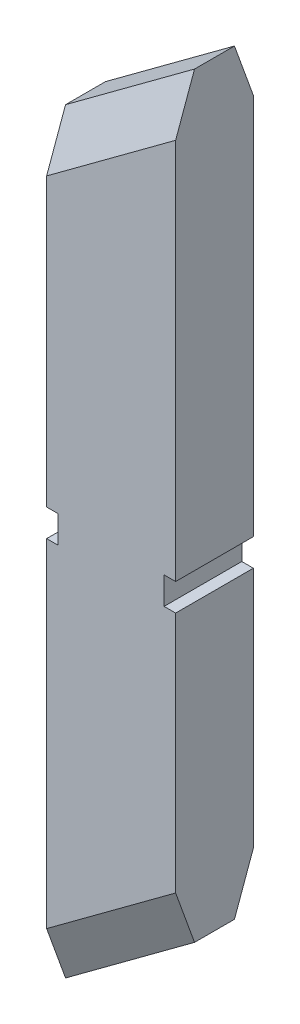
from build123d import *

# Parameters (mm, degrees)
BOSS_EXTRUDE1_DEPTH     = 3.7
CHAMFER1_SIZE           = 0.9
CHAMFER1_SIZE2          = 2
CHAMFER2_SIZE           = 2
CHAMFER2_SIZE2          = 0.9
CHAMFER4_SIZE           = 0.9
CHAMFER4_SIZE2          = 2
CHAMFER5_SIZE           = 2
CHAMFER5_SIZE2          = 0.9
CUT_EXTRUDE2_DEPTH      = 1
CUT_EXTRUDE2_DEPTH_BACK = 4.7
CUT_EXTRUDE4_DEPTH      = 1
CUT_EXTRUDE4_DEPTH_BACK = 4.7


with BuildPart() as part:
    # Sketch1 → Boss-Extrude1 (new body)
    with BuildSketch(Plane.XY):
        Polygon((2.936521739, 23.386304348), (2.936521739, -12.613695652), (-3.203478261, -17.151956522), (-3.203478261, 18.848043478), align=None)
    extrude(amount=BOSS_EXTRUDE1_DEPTH)

    # Chamfer1
    chamfer1_edges = [part.edges().sort_by_distance(p)[0] for p in [
        (-0.133478261, 21.117173913, 3.7),
    ]]
    chamfer1_side = [part.faces().sort_by_distance(p)[0] for p in [
        (-0.133478261, 21.117173913, 1.85),
    ]]
    chamfer(chamfer1_edges, length=CHAMFER1_SIZE, length2=CHAMFER1_SIZE2, reference=chamfer1_side[0])

    # Chamfer2
    chamfer2_edges = [part.edges().sort_by_distance(p)[0] for p in [
        (-0.133478261, 21.117173913, 0),
    ]]
    chamfer2_side = [part.faces().sort_by_distance(p)[0] for p in [
        (-0.133478261, 3.117173913, 0),
    ]]
    chamfer(chamfer2_edges, length=CHAMFER2_SIZE, length2=CHAMFER2_SIZE2, reference=chamfer2_side[0])

    # Chamfer4
    chamfer4_edges = [part.edges().sort_by_distance(p)[0] for p in [
        (-0.133478261, -14.882826087, 3.7),
    ]]
    chamfer4_side = [part.faces().sort_by_distance(p)[0] for p in [
        (-0.133478261, -14.882826087, 1.85),
    ]]
    chamfer(chamfer4_edges, length=CHAMFER4_SIZE, length2=CHAMFER4_SIZE2, reference=chamfer4_side[0])

    # Chamfer5
    chamfer5_edges = [part.edges().sort_by_distance(p)[0] for p in [
        (-0.133478261, -14.882826087, 0),
    ]]
    chamfer5_side = [part.faces().sort_by_distance(p)[0] for p in [
        (-0.133478261, 1.873665248, 0),
    ]]
    chamfer(chamfer5_edges, length=CHAMFER5_SIZE, length2=CHAMFER5_SIZE2, reference=chamfer5_side[0])

    # Sketch2 → Cut-Extrude2 (cut, two sides)
    with BuildSketch(Plane.XY.offset(3.7)) as cut_extrude2_sk:
        Polygon((-58.837345155, 2.711026149), (-3.203478261, 2.711026149), (-2.653478261, 2.711026149), (-2.653478261, 1.411026149), (-3.203478261, 1.411026149), (-58.837345155, 1.411026149), (-170.105078945, 1.411026149), (-170.105078945, 2.711026149), align=None)
    extrude(amount=CUT_EXTRUDE2_DEPTH, mode=Mode.SUBTRACT)
    extrude(cut_extrude2_sk.sketch, amount=-CUT_EXTRUDE2_DEPTH_BACK, mode=Mode.SUBTRACT)

    # Sketch3 → Cut-Extrude4 (cut, two sides)
    with BuildSketch(Plane.XY.offset(3.7)) as cut_extrude4_sk:
        Polygon((58.570388634, 2.711026149), (2.936521739, 2.711026149), (2.386521739, 2.711026149), (2.386521739, 1.411026149), (2.936521739, 1.411026149), (58.570388634, 1.411026149), (169.838122423, 1.411026149), (169.838122423, 2.711026149), align=None)
    extrude(amount=CUT_EXTRUDE4_DEPTH, mode=Mode.SUBTRACT)
    extrude(cut_extrude4_sk.sketch, amount=-CUT_EXTRUDE4_DEPTH_BACK, mode=Mode.SUBTRACT)


solid = part.part
